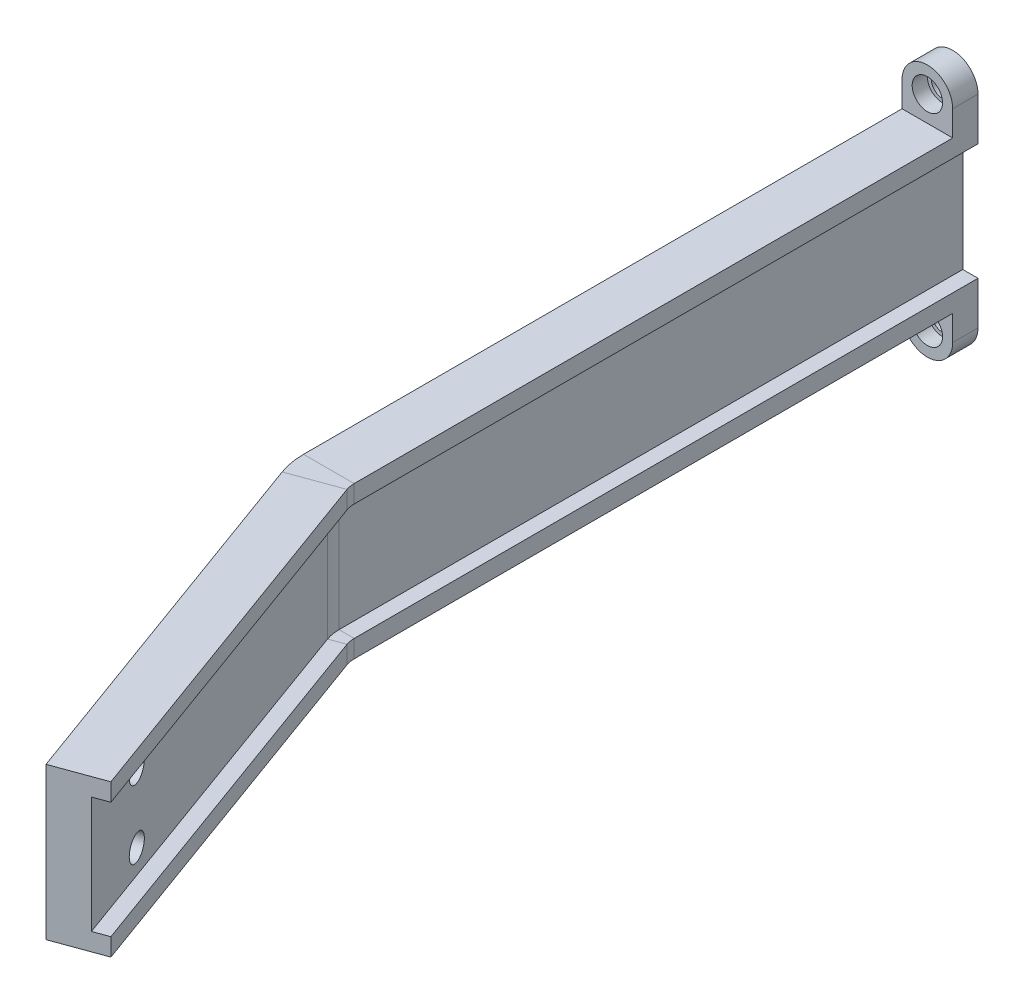
from build123d import *

# Parameters (mm, degrees)
SKETCH_1_R                = 115
SKETCH_1_R_2              = 105
EXTRUDE_1_DEPTH           = 5
SKETCH_4_R                = 2.5
CUT_EXTRUDE_1_DEPTH       = 33.934862746
EXTRUDE_2_DEPTH           = 5
HOLE_WIZARD_1_D           = 4.5
HOLE_WIZARD_1_CBORE_D     = 6
HOLE_WIZARD_1_CBORE_DEPTH = 3
SKETCH_9_R                = 2.25
SKETCH_9_R_2              = 1.9
EXTRUDE_3_DEPTH           = 5
EXTRUDE_4_DEPTH           = 5
HOLE_WIZARD_2_D           = 4.5
HOLE_WIZARD_2_CBORE_D     = 6
HOLE_WIZARD_2_CBORE_DEPTH = 3
SKETCH_13_R               = 2.25
SKETCH_13_R_2             = 1.9
EXTRUDE_5_DEPTH           = 5
SKETCH_14_W               = 562.038590931
SKETCH_14_H               = 462.09177453
CUT_EXTRUDE_4_DEPTH       = 163.29776757
SKETCH_15_W               = 637.223239982
SKETCH_15_H               = 375.31186697
CUT_EXTRUDE_5_DEPTH       = 161


with BuildPart() as part:
    # 草图1 → 凸台-拉伸1 (new body, symmetric)
    with BuildSketch(Plane.XY):
        Circle(SKETCH_1_R)
        Circle(SKETCH_1_R_2, mode=Mode.SUBTRACT)
    extrude(amount=EXTRUDE_1_DEPTH, both=True)

    # 扫描1: sweep along a path in 草图2
    with BuildLine(Plane(origin=(0, 0, 0), x_dir=(1, 0, 0), z_dir=(0, 1, 0))) as sweep_1_path:
        Line((-130, -355), (-156.694693778, -281.656931626))
        ThreePointArc((-156.694693778, -281.656931626), (-157.1458451, -279.97321197), (-157.29776757, -278.236730193))
        Line((-157.29776757, -278.236730193), (-157.29776757, -10))
        ThreePointArc((-157.29776757, -10), (-154.368835382, -2.928932188), (-147.29776757, 0))
        Line((-147.29776757, 0), (-115, 0))
        Line((-115, 0), (-106.681302201, 0))
    # 草图3 → 扫描1 (sweep)
    with BuildSketch(Plane(origin=(-130, 0, 355), x_dir=(0.939692621, 0, -0.342020143), z_dir=(0.342020143, 0, 0.939692621))):
        Polygon((-5, -15), (5, -15), (5, -11.5), (2, -11.5), (2, 11.5), (5, 11.5), (5, 15), (-5, 15), align=None)
    sweep_1 = sweep(path=sweep_1_path.line)

    # 草图4 → 切除-拉伸1 (cut, through all)
    with BuildSketch(Plane(origin=(-227.008304281, 0, 82.624265689), x_dir=(-0.342020143, 0, -0.939692621), z_dir=(0.939692621, 0, -0.342020143))):
        with Locations((-274.128261747, 6.75)):
            Circle(SKETCH_4_R)
        with Locations((-274.128261747, -6.75)):
            Circle(SKETCH_4_R)
    cut_extrude_1 = extrude(amount=-CUT_EXTRUDE_1_DEPTH, mode=Mode.SUBTRACT)

    # 镜向1: 扫描1, 切除-拉伸1 across plane
    add(sweep_1.mirror(Plane(origin=(0, 0, 0), x_dir=(0, 0, 1), z_dir=(1, 0, 0))))
    add(cut_extrude_1.mirror(Plane(origin=(0, 0, 0), x_dir=(0, 0, 1), z_dir=(1, 0, 0))), mode=Mode.SUBTRACT)

    # 草图6 → 凸台-拉伸2 (add, symmetric)
    with BuildSketch(Plane(origin=(0, 0, 0), x_dir=(0, 0, -1), z_dir=(1, 0, 0))):
        with BuildLine():
            Line((-5, 115), (-5, 125))
            ThreePointArc((-5, 125), (0, 130), (5, 125))
            Line((5, 125), (5, 115))
            Line((5, 115), (5, 112.136445143))
            Line((5, 112.136445143), (-5, 112.136445143))
            Line((-5, 112.136445143), (-5, 115))
        make_face()
    extrude_2 = extrude(amount=EXTRUDE_2_DEPTH, both=True)

    # 镜向2: 凸台-拉伸2 across plane
    add(extrude_2.mirror(Plane.ZX))

    # 孔1 (through all)
    with Locations(Plane(origin=(5, 0, 0), x_dir=(0, 0, -1), z_dir=(1, 0, 0))):
        with Locations((0, 124.156343107), (0, -125)):
            CounterBoreHole(HOLE_WIZARD_1_D / 2, HOLE_WIZARD_1_CBORE_D / 2, HOLE_WIZARD_1_CBORE_DEPTH)

    # 草图9 → 凸台-拉伸3 (add)
    with BuildSketch(Plane.ZY.offset(5)):
        with Locations((0, 124.156343107)):
            Circle(SKETCH_9_R)
        with Locations((0, 124.156343107)):
            Circle(SKETCH_9_R_2, mode=Mode.SUBTRACT)
        with Locations((0, -125)):
            Circle(SKETCH_9_R)
        with Locations((0, -125)):
            Circle(SKETCH_9_R_2, mode=Mode.SUBTRACT)
    extrude(amount=-EXTRUDE_3_DEPTH)

    # 草图10 → 凸台-拉伸4 (add, symmetric)
    with BuildSketch(Plane.XY.offset(155)):
        with BuildLine():
            Line((-162.29776757, 15), (-152.29776757, 15))
            Line((-152.29776757, 15), (-152.29776757, 20))
            ThreePointArc((-152.29776757, 20), (-157.29776757, 25), (-162.29776757, 20))
            Line((-162.29776757, 20), (-162.29776757, 15))
        make_face()
        with BuildLine():
            Line((-152.29776757, -15), (-152.29776757, -20))
            ThreePointArc((-152.29776757, -20), (-157.29776757, -25), (-162.29776757, -20))
            Line((-162.29776757, -20), (-162.29776757, -15))
            Line((-162.29776757, -15), (-152.29776757, -15))
        make_face()
        with BuildLine():
            Line((162.29776757, -15), (152.29776757, -15))
            Line((152.29776757, -15), (152.29776757, -20))
            ThreePointArc((152.29776757, -20), (157.29776757, -25), (162.29776757, -20))
            Line((162.29776757, -20), (162.29776757, -15))
        make_face()
        with BuildLine():
            Line((152.29776757, 15), (152.29776757, 20))
            ThreePointArc((152.29776757, 20), (157.29776757, 25), (162.29776757, 20))
            Line((162.29776757, 20), (162.29776757, 15))
            Line((162.29776757, 15), (152.29776757, 15))
        make_face()
    extrude(amount=EXTRUDE_4_DEPTH, both=True)

    # 孔2 (through all)
    with Locations(Plane.XY.offset(160)):
        with Locations((-157.29776757, 20), (-157.29776757, -20), (157.29776757, 20), (157.29776757, -20)):
            CounterBoreHole(HOLE_WIZARD_2_D / 2, HOLE_WIZARD_2_CBORE_D / 2, HOLE_WIZARD_2_CBORE_DEPTH)

    # 草图13 → 凸台-拉伸5 (add)
    with BuildSketch(Plane(origin=(0, 0, 150), x_dir=(-1, 0, 0), z_dir=(0, 0, -1))):
        with Locations((-157.29776757, 20)):
            Circle(SKETCH_13_R)
        with Locations((-157.29776757, 20)):
            Circle(SKETCH_13_R_2, mode=Mode.SUBTRACT)
        with Locations((-157.29776757, -20)):
            Circle(SKETCH_13_R)
        with Locations((-157.29776757, -20)):
            Circle(SKETCH_13_R_2, mode=Mode.SUBTRACT)
        with Locations((157.29776757, -20)):
            Circle(SKETCH_13_R)
        with Locations((157.29776757, -20)):
            Circle(SKETCH_13_R_2, mode=Mode.SUBTRACT)
        with Locations((157.29776757, 20)):
            Circle(SKETCH_13_R)
        with Locations((157.29776757, 20)):
            Circle(SKETCH_13_R_2, mode=Mode.SUBTRACT)
    extrude(amount=-EXTRUDE_5_DEPTH)

    # 草图14 → 切除-拉伸4 (cut, through all)
    with BuildSketch(Plane(origin=(0, 0, 0), x_dir=(0, 0, -1), z_dir=(1, 0, 0))):
        with Locations((-153.139864812, -31.152254463)):
            Rectangle(SKETCH_14_W, SKETCH_14_H)
    extrude(amount=CUT_EXTRUDE_4_DEPTH, mode=Mode.SUBTRACT)

    # 草图15 → 切除-拉伸5 (cut, through all)
    with BuildSketch(Plane.XY.offset(155)):
        Rectangle(SKETCH_15_W, SKETCH_15_H)
    extrude(amount=-CUT_EXTRUDE_5_DEPTH, mode=Mode.SUBTRACT)


solid = part.part
